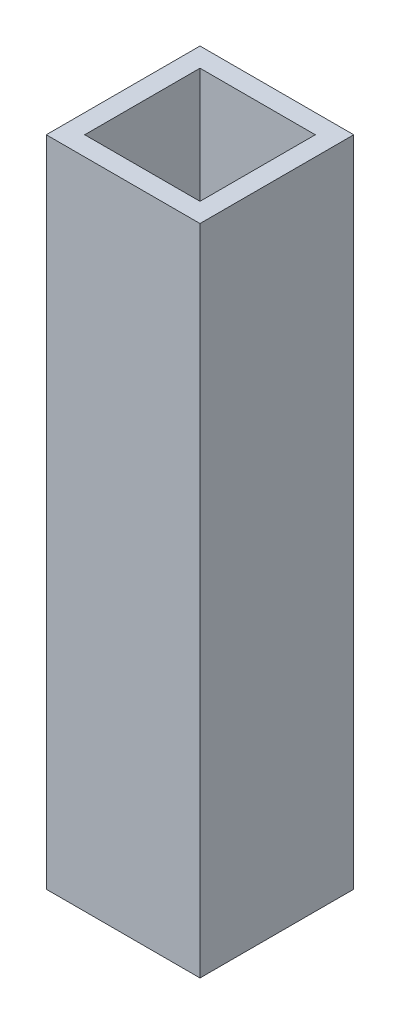
from build123d import *

# Parameters (mm, degrees)
SKETCH1_W           = 25.4
SKETCH1_H           = 25.4
SKETCH1_W_2         = 19.05
SKETCH1_H_2         = 19.05
BOSS_EXTRUDE1_DEPTH = 107.95


with BuildPart() as part:
    # Sketch1 → Boss-Extrude1 (new body)
    with BuildSketch(Plane(origin=(0, 0, 0), x_dir=(1, 0, 0), z_dir=(0, 1, 0))):
        Rectangle(SKETCH1_W, SKETCH1_H)
        Rectangle(SKETCH1_W_2, SKETCH1_H_2, mode=Mode.SUBTRACT)
    extrude(amount=BOSS_EXTRUDE1_DEPTH)


solid = part.part
